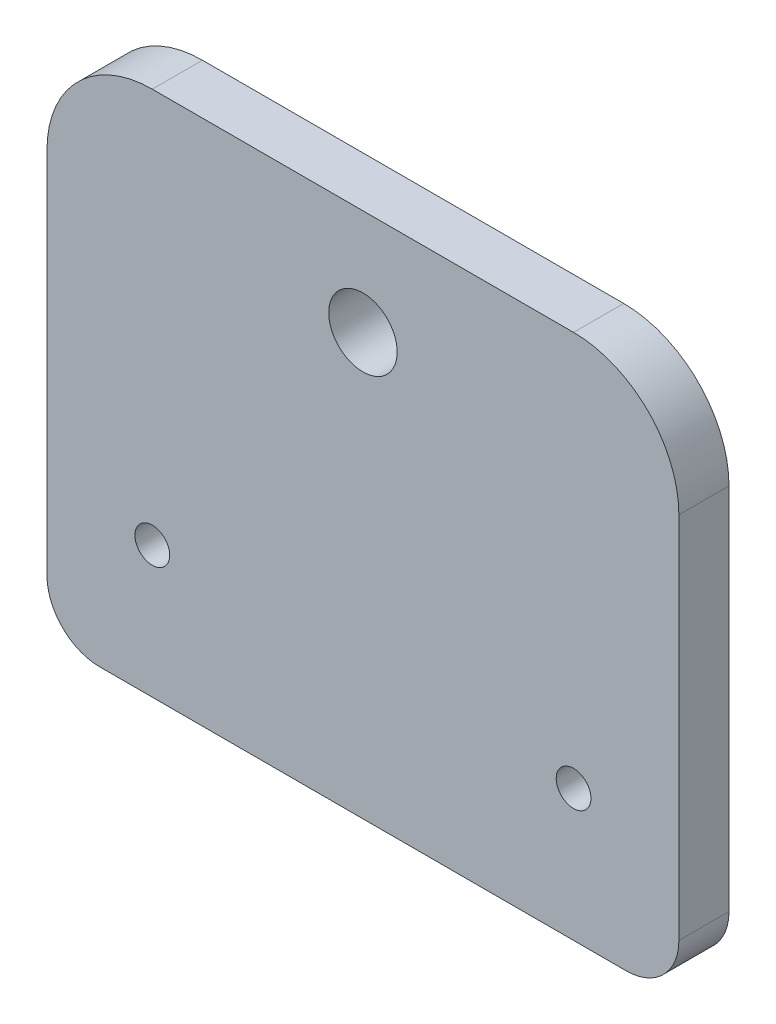
from build123d import *

# Parameters (mm, degrees)
SKETCH1_W           = 60
SKETCH1_H           = 50
BOSS_EXTRUDE1_DEPTH = 4.76
SKETCH2_R           = 1.65
SKETCH2_R_2         = 3.25
CUT_EXTRUDE1_DEPTH  = 5.76
FILLET1_R           = 10
FILLET2_R           = 5


with BuildPart() as part:
    # Sketch1 → Boss-Extrude1 (new body)
    with BuildSketch(Plane.XY):
        with Locations((30, 25)):
            Rectangle(SKETCH1_W, SKETCH1_H)
    extrude(amount=BOSS_EXTRUDE1_DEPTH)

    # Sketch2 → Cut-Extrude1 (cut, through all)
    with BuildSketch(Plane.XY.offset(4.76)):
        with Locations((10, 12.5)):
            Circle(SKETCH2_R)
        with Locations((50, 12.5)):
            Circle(SKETCH2_R)
        with Locations((30, 40)):
            Circle(SKETCH2_R_2)
    extrude(amount=-CUT_EXTRUDE1_DEPTH, mode=Mode.SUBTRACT)

    # Fillet1
    fillet1_edges = [part.edges().sort_by_distance(p)[0] for p in [
        (0, 50, 2.38),
        (60, 50, 2.38),
    ]]
    fillet(fillet1_edges, radius=FILLET1_R)

    # Fillet2
    fillet2_edges = [part.edges().sort_by_distance(p)[0] for p in [
        (60, 0, 2.38),
        (0, 0, 2.38),
    ]]
    fillet(fillet2_edges, radius=FILLET2_R)


solid = part.part
